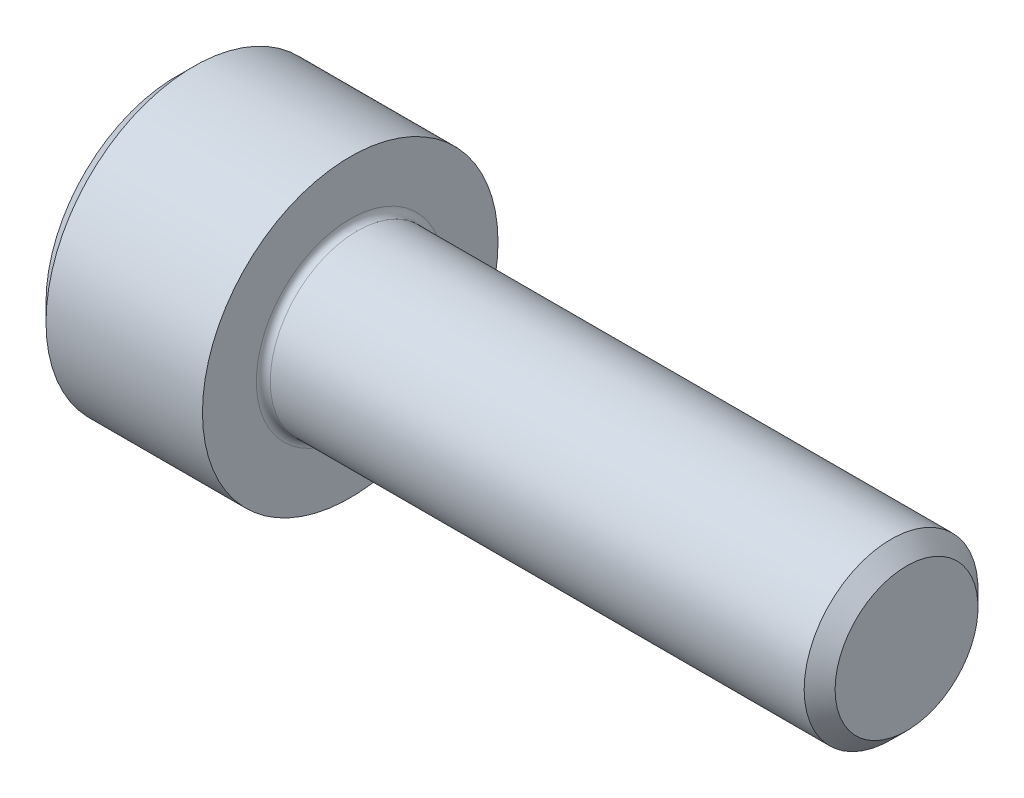
from build123d import *

# Parameters (mm, degrees)
FILLET1_R   = 0.2
HEX_2_DEPTH = 2.5


with BuildPart() as part:
    # BodySke → Base-Revolve (revolve)
    with BuildSketch(Plane.XY):
        Polygon((0, 0), (0, 3.75), (0.5, 4.25), (5, 4.25), (5, 2.5), (20.555, 2.5), (21, 2.055), (21, 0), align=None)
    revolve(axis=Axis((-31.75, 0, 0), (1, 0, 0)))

    # Fillet1
    fillet1_edges = [part.edges().sort_by_distance(p)[0] for p in [
        (5, -2.5, 0),
    ]]
    fillet(fillet1_edges, radius=FILLET1_R)

    # Sketch2 → Hex-PreBroach (revolve, cut)
    with BuildSketch(Plane.XY):
        Polygon((0, 2.042), (2.5, 2.042), (3.67894925, 0), (0, 0), align=None)
    revolve(axis=Axis((0, 0, 0), (1, 0, 0)), mode=Mode.SUBTRACT)

    # Sketch3 → Hex 2 (cut)
    with BuildSketch(Plane(origin=(0, 0, 0), x_dir=(0, 0.5, 0.866025404), z_dir=(-1, 0, 0))):
        Polygon((1.17894925, 2.042), (-1.17894925, 2.042), (-2.357898499, 0), (-1.17894925, -2.042), (1.17894925, -2.042), (2.357898499, 0), align=None)
    extrude(amount=-HEX_2_DEPTH, mode=Mode.SUBTRACT)


solid = part.part
